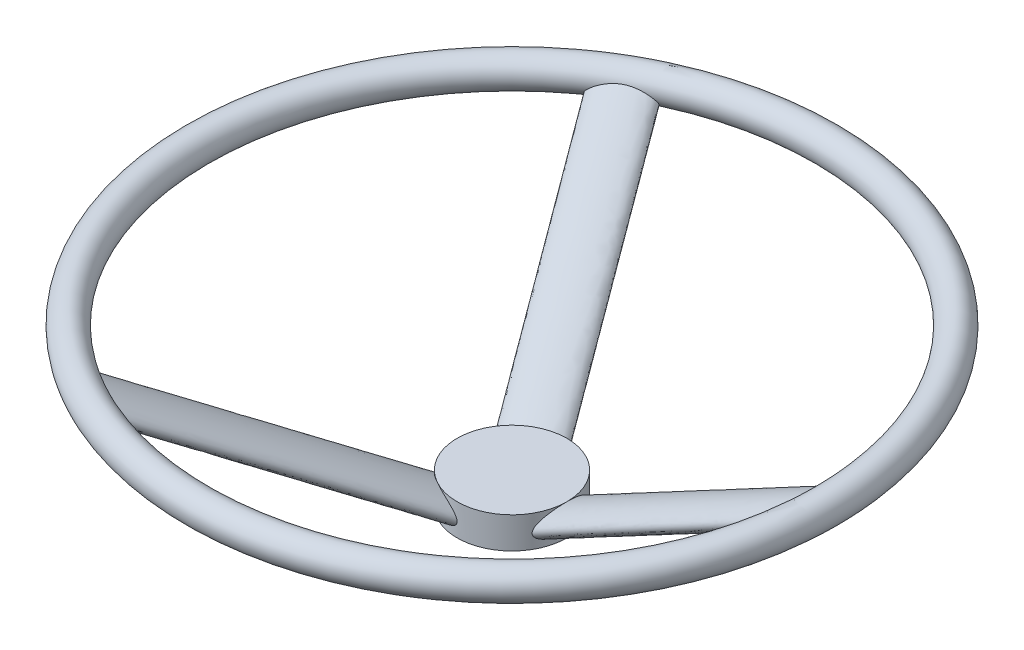
from build123d import *
from build123d.topology import SkipClean

# Parameters (mm, degrees)
SKETCH1_R                = 10
SKETCH1_W                = 35
SKETCH1_H                = 20
BOSS_EXTRUDE1_REACH      = 473.381
BOSS_EXTRUDE1_END_RADIUS = 35
SKETCH3_RX               = 17.5
SKETCH3_RY               = 7.5
CIRPATTERN1_COUNT        = 3


with BuildPart() as part:
    # Sketch1 → Revolve1 (revolve)
    with BuildSketch(Plane.XY, mode=Mode.PRIVATE) as revolve1_sk:
        with Locations((200, 100)):
            Circle(SKETCH1_R)
        with Locations((17.5, 10)):
            Rectangle(SKETCH1_W, SKETCH1_H)
    revolve(revolve1_sk.sketch.rotate(Axis((0, 0, 0), (0, 1, 0)), 90), axis=Axis((0, 0, 0), (0, 1, 0)))

    # Boss-Extrude1: up to this cylinder (the profile starts outside it)
    boss_extrude1_end = Plane(origin=(0, 99.622766, 0), z_dir=(0, -1, 0)) * Cylinder(BOSS_EXTRUDE1_END_RADIUS, 1017.762, mode=Mode.PRIVATE)
    # Sketch3 → Boss-Extrude1 (add, up to the surface)
    with BuildSketch(Plane(origin=(200, 100, 0), x_dir=(0, 0, -1), z_dir=(0.8823529411764706, 0.47058823529411786, 0)), mode=Mode.PRIVATE) as boss_extrude1_sk1:
        with Locations(Location((0, -0.427531823), (0, 0, 0))):
            Ellipse(SKETCH3_RX, SKETCH3_RY)
    boss_extrude1_tool1 = extrude(boss_extrude1_sk1.sketch, amount=-BOSS_EXTRUDE1_REACH, mode=Mode.PRIVATE) - boss_extrude1_end
    boss_extrude1 = boss_extrude1_tool1.solids().sort_by_distance((200.201191, 99.622766, 0))[0]
    add(boss_extrude1)

    # CirPattern1: Boss-Extrude1 ×3 about axis
    with SkipClean():  # the faces are left unmerged after this step: merging them gives an invalid solid
        cirpattern1_axis = Axis((0, 0, 0), (0, -1, 0))
        for i in range(1, CIRPATTERN1_COUNT):
            add(boss_extrude1.rotate(cirpattern1_axis, i * 360 / CIRPATTERN1_COUNT))


solid = part.part
